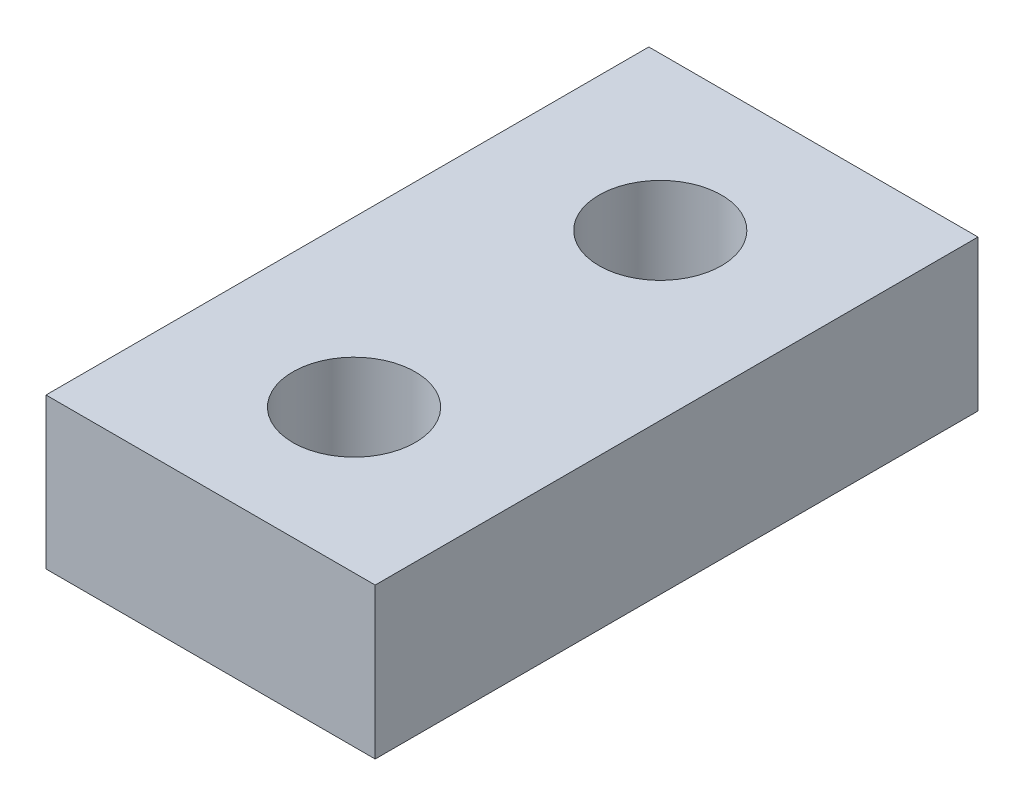
from build123d import *

# Parameters (mm, degrees)
SKETCH1_W           = 10.922
SKETCH1_H           = 20
SKETCH1_R           = 2.032
BOSS_EXTRUDE1_DEPTH = 5


with BuildPart() as part:
    # Sketch1 → Boss-Extrude1 (new body)
    with BuildSketch(Plane(origin=(0, 0, 0), x_dir=(1, 0, 0), z_dir=(0, 1, 0))):
        with Locations((5.461, 10)):
            Rectangle(SKETCH1_W, SKETCH1_H)
        with Locations((5.461, 14.92)):
            Circle(SKETCH1_R, mode=Mode.SUBTRACT)
        with Locations((5.461, 4.76)):
            Circle(SKETCH1_R, mode=Mode.SUBTRACT)
    extrude(amount=BOSS_EXTRUDE1_DEPTH)


solid = part.part
